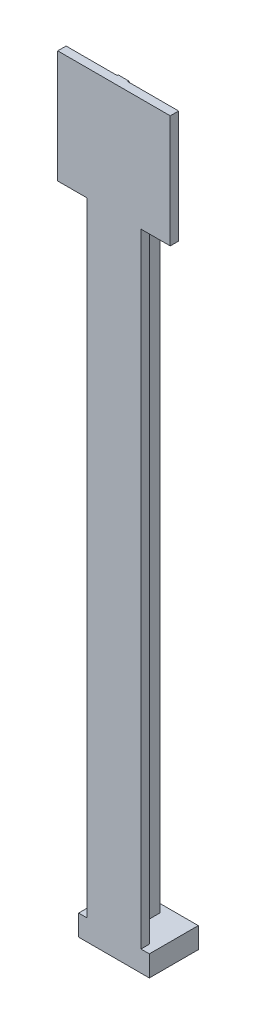
from build123d import *

# Parameters (mm, degrees)
SKETCH1_W           = 16.9
SKETCH1_H           = 11.7
BOSS_EXTRUDE1_DEPTH = 5
SKETCH2_W           = 11.05
SKETCH2_H           = 5.85
CUT_EXTRUDE1_DEPTH  = 0.95
SKETCH3_W           = 10.2
SKETCH3_H           = 5.1
CUT_EXTRUDE2_DEPTH  = 3
SKETCH4_W           = 10.2
SKETCH4_H           = 5.1
BOSS_EXTRUDE2_DEPTH = 1
BOSS_EXTRUDE3_DEPTH = 176
SKETCH6_W           = 26.9
SKETCH6_H           = 26.95
BOSS_EXTRUDE4_DEPTH = 2
CHAMFER1_SIZE       = 14
CHAMFER1_SIZE2      = 7.443932043


with BuildPart() as part:
    # Sketch1 → Boss-Extrude1 (new body)
    with BuildSketch(Plane(origin=(0, 0, 0), x_dir=(1, 0, 0), z_dir=(0, 1, 0))):
        with Locations((8.45, 5.85)):
            Rectangle(SKETCH1_W, SKETCH1_H)
    extrude(amount=BOSS_EXTRUDE1_DEPTH)

    # Sketch2 → Cut-Extrude1 (cut)
    with BuildSketch(Plane.XZ):
        with Locations((8.45, -5.85)):
            Rectangle(SKETCH2_W, SKETCH2_H)
    extrude(amount=-CUT_EXTRUDE1_DEPTH, mode=Mode.SUBTRACT)

    # Sketch3 → Cut-Extrude2 (cut)
    with BuildSketch(Plane.XZ.offset(-0.95)):
        with Locations((8.475, -5.875)):
            Rectangle(SKETCH3_W, SKETCH3_H)
    extrude(amount=-CUT_EXTRUDE2_DEPTH, mode=Mode.SUBTRACT)

    # Sketch4 → Boss-Extrude2 (add)
    with BuildSketch(Plane.XZ.offset(-0.95)):
        with Locations((8.475, -5.875)):
            Rectangle(SKETCH4_W, SKETCH4_H)
    extrude(amount=-BOSS_EXTRUDE2_DEPTH)

    # Sketch5 → Boss-Extrude3 (add)
    with BuildSketch(Plane(origin=(0, 5, 0), x_dir=(1, 0, 0), z_dir=(0, 1, 0))):
        Polygon((2, 0), (2, 2), (7.2, 2), (7.2, 9.7), (9.7, 9.7), (9.7, 2), (14.9, 2), (14.9, 0), align=None)
    extrude(amount=BOSS_EXTRUDE3_DEPTH)

    # Sketch6 → Boss-Extrude4 (add)
    with BuildSketch(Plane.XY):
        with Locations((8.45, 167.525)):
            Rectangle(SKETCH6_W, SKETCH6_H)
    extrude(amount=-BOSS_EXTRUDE4_DEPTH)

    # Chamfer1
    chamfer1_edges = [part.edges().sort_by_distance(p)[0] for p in [
        (8.45, 181, -9.7),
    ]]
    chamfer1_side = [part.faces().sort_by_distance(p)[0] for p in [
        (8.45, 93, -9.7),
    ]]
    chamfer(chamfer1_edges, length=CHAMFER1_SIZE, length2=CHAMFER1_SIZE2, reference=chamfer1_side[0])


solid = part.part
